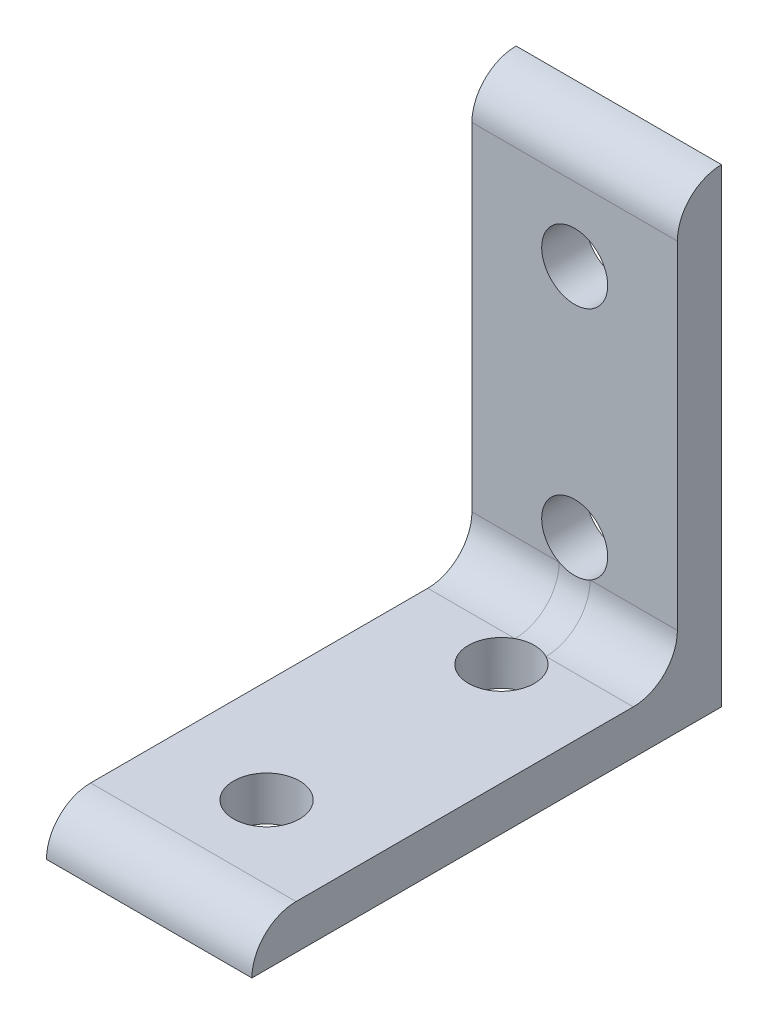
from build123d import *

# Parameters (mm, degrees)
EXTRUDE1_DEPTH     = 22.225
SKETCH2_R          = 3.5687
CUT_EXTRUDE1_DEPTH = 5.7752
FILLET1_R          = 4.7752


with BuildPart() as part:
    # Sketch1 → Extrude1 (new body)
    with BuildSketch(Plane(origin=(0, 0, 0), x_dir=(0, 0, -1), z_dir=(1, 0, 0))):
        with BuildLine():
            Line((-28.199163803, 21.897674685), (22.600836197, 21.897674685))
            Line((22.600836197, 21.897674685), (17.825636197, 26.672874685))
            Line((17.825636197, 26.672874685), (-23.423963803, 26.672874685))
            ThreePointArc((-23.423963803, 26.672874685), (-26.800540105, 25.274250987), (-28.199163803, 21.897674685))
        make_face()
    extrude(amount=EXTRUDE1_DEPTH)

    # Sketch2 → Cut-Extrude1 (cut, through all)
    with BuildSketch(Plane(origin=(0, 26.672874685, 0), x_dir=(1, 0, 0), z_dir=(0, 1, 0))):
        with Locations((11.1125, -15.499163803)):
            Circle(SKETCH2_R)
        with Locations((11.1125, 9.900836197)):
            Circle(SKETCH2_R)
    extrude(amount=-CUT_EXTRUDE1_DEPTH, mode=Mode.SUBTRACT)

    # Mirror1: part across plane


with BuildPart() as part_1:
    add(part.part)
    add(part.part.mirror(Plane(origin=(22.225, 21.897674685, -22.600836197), x_dir=(0, 0.707106781, 0.707106781), z_dir=(0, -0.707106781, 0.707106781))))

    # Fillet1
    fillet1_edges = [part_1.edges().sort_by_distance(p)[0] for p in [
        (11.1125, 26.672874685, -17.825636197),
    ]]
    fillet(fillet1_edges, radius=FILLET1_R)


solid = part_1.part
